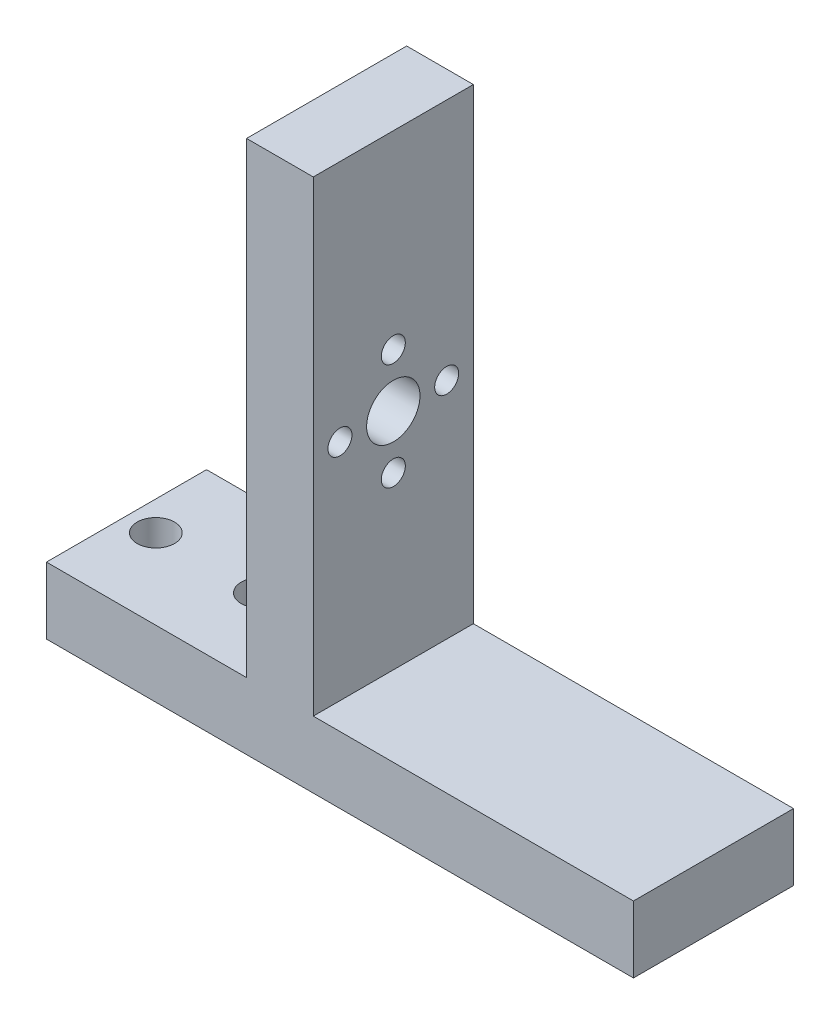
from build123d import *

# Parameters (mm, degrees)
BOSS_EXTRUDE1_DEPTH = 15.24
SKETCH5_R           = 1.143
SKETCH5_R_2         = 2.54
CUT_EXTRUDE1_DEPTH  = 15.24
SKETCH6_R           = 1.778
CUT_EXTRUDE2_DEPTH  = 15.24


with BuildPart() as part:
    # Sketch2 → Boss-Extrude1 (new body)
    with BuildSketch(Plane.XY):
        Polygon((-27.94, 0), (27.94, 0), (27.94, 6.35), (-2.54, 6.35), (-2.54, 50.8), (-8.89, 50.8), (-8.89, 6.35), (-27.94, 6.35), align=None)
    extrude(amount=BOSS_EXTRUDE1_DEPTH)

    # Sketch5 → Cut-Extrude1 (cut)
    with BuildSketch(Plane.ZY.offset(8.89)):
        with Locations((7.62, 32.766)):
            Circle(SKETCH5_R)
        with Locations((7.62, 27.686)):
            Circle(SKETCH5_R_2)
        with Locations((12.7, 27.686)):
            Circle(SKETCH5_R)
        with Locations((7.62, 22.606)):
            Circle(SKETCH5_R)
        with Locations((2.54, 27.686)):
            Circle(SKETCH5_R)
    extrude(amount=-CUT_EXTRUDE1_DEPTH, mode=Mode.SUBTRACT)

    # Sketch6 → Cut-Extrude2 (cut)
    with BuildSketch(Plane(origin=(0, 6.35, 0), x_dir=(1, 0, 0), z_dir=(0, 1, 0))):
        with Locations((-25.146, -7.62)):
            Circle(SKETCH6_R)
        with Locations((-15.24, -7.62)):
            Circle(SKETCH6_R)
    extrude(amount=-CUT_EXTRUDE2_DEPTH, mode=Mode.SUBTRACT)


solid = part.part
